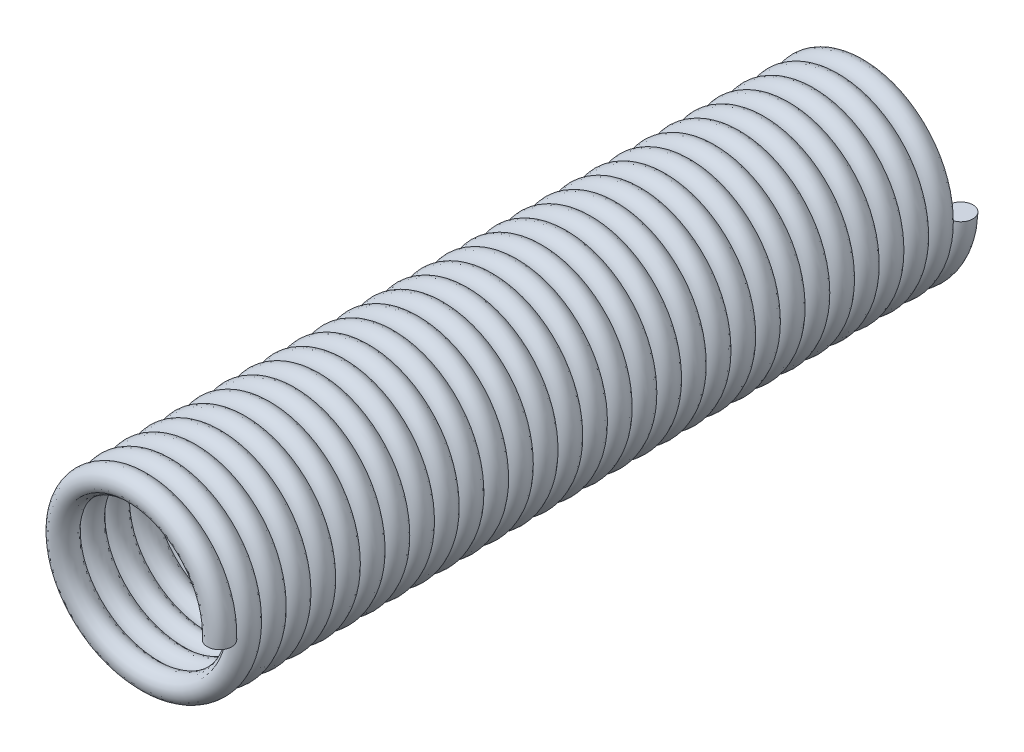
from build123d import *

# Parameters (mm, degrees)
SWEEP1_PITCH       = 1.6256
SWEEP1_HEIGHT      = 48.768
SWEEP1_RADIUS      = 5.5499
SWEEP1_START_ANGLE = -180
SKETCH2_R          = 0.8001


with BuildPart() as part:
    # Sweep1: sweep along a helix
    with BuildLine() as sweep1_path:
        add(Helix(SWEEP1_PITCH, SWEEP1_HEIGHT, SWEEP1_RADIUS, center=(0, 0, 0), direction=(0, 0, -1), lefthand=True, mode=Mode.PRIVATE).rotate(Axis((0, 0, 0), (0, 0, -1)), SWEEP1_START_ANGLE))
    # Sketch2 → Sweep1 (sweep)
    with BuildSketch(Plane(origin=(0, 0, 0), x_dir=(1, 0, 0), z_dir=(0, 1, 0))):
        with Locations((5.5499, 0)):
            Circle(SKETCH2_R)
    sweep(path=sweep1_path.line, is_frenet=True)


solid = part.part
